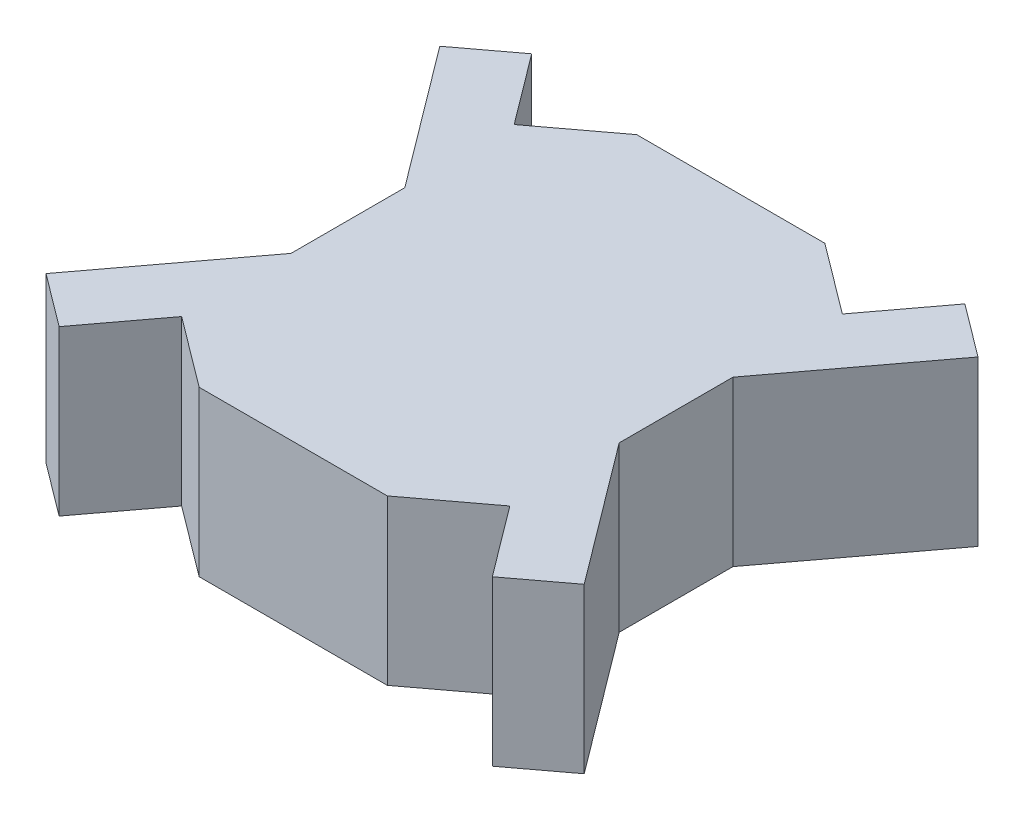
from build123d import *

# Parameters (mm, degrees)
BOSS_EXTRUDE1_DEPTH = 75


with BuildPart() as part:
    # Sketch1 → Boss-Extrude1 (new body)
    with BuildSketch(Plane(origin=(0, 0, 0), x_dir=(1, 0, 0), z_dir=(0, 1, 0))):
        Polygon((43, 100), (-43, 100), (-75, 76), (-99, 108), (-123, 90), (-75, 26), (-75, -26), (-123, -90), (-99, -108), (-75, -76), (-43, -100), (43, -100), (75, -76), (99, -108), (123, -90), (75, -26), (75, 26), (123, 90), (99, 108), (75, 76), align=None)
    extrude(amount=BOSS_EXTRUDE1_DEPTH)


solid = part.part
